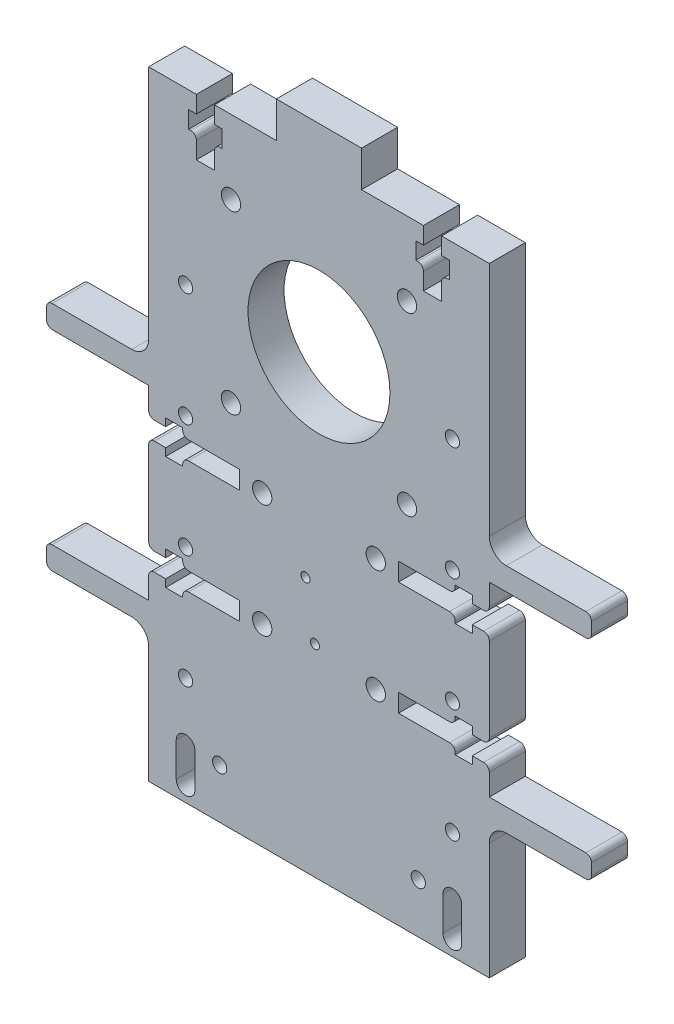
from build123d import *

# Parameters (mm, degrees)
BOSS_EXTRUDE1_DEPTH            = 6.35
FILLET1_R                      = 1
FILLET3_R                      = 3
M2_TAPPED_HOLE1_D              = 1.6
M2_TAPPED_HOLE2_D              = 1.6
M3_CLEARANCE_HOLE1_D           = 3.4
M3_CLEARANCE_HOLE2_D           = 3.4
M3_CLEARANCE_HOLE3_D           = 3.4
M3_CLEARANCE_HOLE4_D           = 3.4
M3_TAPPED_HOLE2_D              = 2.5
M3_TAPPED_HOLE3_D              = 2.5
M3_TAPPED_HOLE4_D              = 2.5
M3_TAPPED_HOLE5_D              = 2.5
M3_TAPPED_HOLE6_D              = 2.5
M3_TAPPED_HOLE7_D              = 2.5
M3_TAPPED_HOLE8_D              = 2.5
M3_TAPPED_HOLE9_D              = 2.5
M3_TAPPED_HOLE10_D             = 2.5
M3_CLEARANCE_HOLE8_D           = 3.4
M3_CLEARANCE_HOLE7_D           = 3.4
M3_TAPPED_HOLE1_D              = 2.5
M3_CLEARANCE_HOLE6_D           = 3.4
F_25_0_25_DIAMETER_HOLE1_D     = 25
F_25_0_25_DIAMETER_HOLE1_DEPTH = 6.35
M3_CLEARANCE_HOLE5_D           = 3.4
FILLET4_R                      = 1


with BuildPart() as part:
    # Sketch1 → Boss-Extrude1 (new body)
    with BuildSketch(Plane.XY.offset(6.35)):
        Polygon((48, -56.9), (48, -52.9), (30, -52.9), (30, -48.1), (27, -48.1), (27, -49.45), (24, -49.45), (24, -48.1), (14, -48.1), (14, -44.9), (24, -44.9), (24, -43.55), (27, -43.55), (27, -44.9), (30, -44.9), (30, -28.1), (27, -28.1), (27, -29.45), (24, -29.45), (24, -28.1), (14, -28.1), (14, -24.9), (24, -24.9), (24, -23.55), (27, -23.55), (27, -24.9), (30, -24.9), (30, -20.1), (48, -20.1), (48, -16.1), (30, -16.1), (30, 28.5), (21.6, 28.5), (21.6, 25.5), (22.95, 25.5), (22.95, 22.5), (21.6, 22.5), (21.6, 18.5), (18.4, 18.5), (18.4, 22.5), (17.05, 22.5), (17.05, 25.5), (18.4, 25.5), (18.4, 28.5), (7.5, 28.5), (7.5, 34.85), (-7.5, 34.85), (-7.5, 28.5), (-18.4, 28.5), (-18.4, 25.5), (-17.05, 25.5), (-17.05, 22.5), (-18.4, 22.5), (-18.4, 18.5), (-21.6, 18.5), (-21.6, 22.5), (-22.95, 22.5), (-22.95, 25.5), (-21.6, 25.5), (-21.6, 28.5), (-30, 28.5), (-30, -16.1), (-48, -16.1), (-48, -20.1), (-30, -20.1), (-30, -24.9), (-27, -24.9), (-27, -23.55), (-24, -23.55), (-24, -24.9), (-14, -24.9), (-14, -28.1), (-24, -28.1), (-24, -29.45), (-27, -29.45), (-27, -28.1), (-30, -28.1), (-30, -44.9), (-27, -44.9), (-27, -43.55), (-24, -43.55), (-24, -44.9), (-14, -44.9), (-14, -48.1), (-24, -48.1), (-24, -49.45), (-27, -49.45), (-27, -48.1), (-30, -48.1), (-30, -52.9), (-48, -52.9), (-48, -56.9), (-30, -56.9), (-30, -80.5), (30, -80.5), (30, -56.9), align=None)
        with BuildLine():
            Line((-21.842448699, -71.75), (-21.842448699, -77.75))
            ThreePointArc((-21.842448699, -77.75), (-23.492448699, -79.4), (-25.142448699, -77.75))
            Line((-25.142448699, -77.75), (-25.142448699, -71.75))
            ThreePointArc((-25.142448699, -71.75), (-23.492448699, -70.1), (-21.842448699, -71.75))
        make_face(mode=Mode.SUBTRACT)
        with BuildLine():
            Line((21.842448699, -77.75), (21.842448699, -71.75))
            ThreePointArc((21.842448699, -71.75), (23.492448699, -70.1), (25.142448699, -71.75))
            Line((25.142448699, -71.75), (25.142448699, -77.75))
            ThreePointArc((25.142448699, -77.75), (23.492448699, -79.4), (21.842448699, -77.75))
        make_face(mode=Mode.SUBTRACT)
    extrude(amount=-BOSS_EXTRUDE1_DEPTH)

    # Fillet1
    fillet1_edges = [part.edges().sort_by_distance(p)[0] for p in [
        (-48, -56.9, 3.175),
        (-48, -52.9, 3.175),
        (-30, -48.1, 3.175),
        (-24, -48.1, 3.175),
        (-24, -44.9, 3.175),
        (-30, -44.9, 3.175),
        (-30, -28.1, 3.175),
        (-24, -28.1, 3.175),
        (-24, -24.9, 3.175),
        (-30, -24.9, 3.175),
        (-48, -20.1, 3.175),
        (-48, -16.1, 3.175),
        (48, -16.1, 3.175),
        (48, -20.1, 3.175),
        (30, -24.9, 3.175),
        (24, -24.9, 3.175),
        (24, -28.1, 3.175),
        (30, -28.1, 3.175),
        (30, -44.9, 3.175),
        (24, -44.9, 3.175),
        (24, -48.1, 3.175),
        (30, -48.1, 3.175),
        (48, -52.9, 3.175),
        (48, -56.9, 3.175),
    ]]
    fillet(fillet1_edges, radius=FILLET1_R)

    # Fillet3
    fillet3_edges = [part.edges().sort_by_distance(p)[0] for p in [
        (30, -56.9, 3.175),
        (-30, -56.9, 3.175),
        (-30, -16.1, 3.175),
        (30, -16.1, 3.175),
    ]]
    fillet(fillet3_edges, radius=FILLET3_R)

    # M2 Tapped Hole1 (through all)
    with Locations(Plane.XY.offset(6.35)):
        with Locations((-2.359287388, -35.545092005)):
            Hole(M2_TAPPED_HOLE1_D / 2)

    # M2 Tapped Hole2 (through all)
    with Locations(Plane.XY.offset(6.35)):
        with Locations((-0.7096297, -44.900765659)):
            Hole(M2_TAPPED_HOLE2_D / 2)

    # M3 Clearance Hole1 (through all)
    with Locations(Plane.XY.offset(6.35)):
        with Locations((15.5, 15.5)):
            Hole(M3_CLEARANCE_HOLE1_D / 2)

    # M3 Clearance Hole2 (through all)
    with Locations(Plane.XY.offset(6.35)):
        with Locations((-15.5, -15.5)):
            Hole(M3_CLEARANCE_HOLE2_D / 2)

    # M3 Clearance Hole3 (through all)
    with Locations(Plane.XY.offset(6.35)):
        with Locations((15.5, -15.5)):
            Hole(M3_CLEARANCE_HOLE3_D / 2)

    # M3 Clearance Hole4 (through all)
    with Locations(Plane.XY.offset(6.35)):
        with Locations((-15.5, 15.5)):
            Hole(M3_CLEARANCE_HOLE4_D / 2)

    # M3 Tapped Hole2 (through all)
    with Locations(Plane.XY.offset(6.35)):
        with Locations((23.5, -61.5)):
            Hole(M3_TAPPED_HOLE2_D / 2)

    # M3 Tapped Hole3 (through all)
    with Locations(Plane.XY.offset(6.35)):
        with Locations((23.5, -41.5)):
            Hole(M3_TAPPED_HOLE3_D / 2)

    # M3 Tapped Hole4 (through all)
    with Locations(Plane.XY.offset(6.35)):
        with Locations((23.5, -21.5)):
            Hole(M3_TAPPED_HOLE4_D / 2)

    # M3 Tapped Hole5 (through all)
    with Locations(Plane.XY.offset(6.35)):
        with Locations((23.5, -1.5)):
            Hole(M3_TAPPED_HOLE5_D / 2)

    # M3 Tapped Hole6 (through all)
    with Locations(Plane.XY.offset(6.35)):
        with Locations((-17.492448699, -71.75)):
            Hole(M3_TAPPED_HOLE6_D / 2)

    # M3 Tapped Hole7 (through all)
    with Locations(Plane.XY.offset(6.35)):
        with Locations((17.492448699, -71.75)):
            Hole(M3_TAPPED_HOLE7_D / 2)

    # M3 Tapped Hole8 (through all)
    with Locations(Plane.XY.offset(6.35)):
        with Locations((-23.5, -41.5)):
            Hole(M3_TAPPED_HOLE8_D / 2)

    # M3 Tapped Hole9 (through all)
    with Locations(Plane.XY.offset(6.35)):
        with Locations((-23.5, -61.5)):
            Hole(M3_TAPPED_HOLE9_D / 2)

    # M3 Tapped Hole10 (through all)
    with Locations(Plane.XY.offset(6.35)):
        with Locations((-23.5, -21.5)):
            Hole(M3_TAPPED_HOLE10_D / 2)

    # M3 Clearance Hole8 (through all)
    with Locations(Plane.XY.offset(6.35)):
        with Locations((-10, -46.5)):
            Hole(M3_CLEARANCE_HOLE8_D / 2)

    # M3 Clearance Hole7 (through all)
    with Locations(Plane.XY.offset(6.35)):
        with Locations((10, -46.5)):
            Hole(M3_CLEARANCE_HOLE7_D / 2)

    # M3 Tapped Hole1 (through all)
    with Locations(Plane.XY.offset(6.35)):
        with Locations((-23.5, -1.5)):
            Hole(M3_TAPPED_HOLE1_D / 2)

    # M3 Clearance Hole6 (through all)
    with Locations(Plane.XY.offset(6.35)):
        with Locations((10, -26.5)):
            Hole(M3_CLEARANCE_HOLE6_D / 2)

    # Ø25.0 (25) Diameter Hole1
    with Locations(Plane.XY.offset(6.35)):
        with Locations((0, 0)):
            Hole(F_25_0_25_DIAMETER_HOLE1_D / 2, depth=F_25_0_25_DIAMETER_HOLE1_DEPTH)

    # M3 Clearance Hole5 (through all)
    with Locations(Plane.XY.offset(6.35)):
        with Locations((-10, -26.5)):
            Hole(M3_CLEARANCE_HOLE5_D / 2)

    # Fillet4
    fillet4_edges = [part.edges().sort_by_distance(p)[0] for p in [
        (-21.6, 22.5, 3.175),
        (-18.4, 22.5, 3.175),
        (18.4, 22.5, 3.175),
        (21.6, 22.5, 3.175),
    ]]
    fillet(fillet4_edges, radius=FILLET4_R)


solid = part.part
